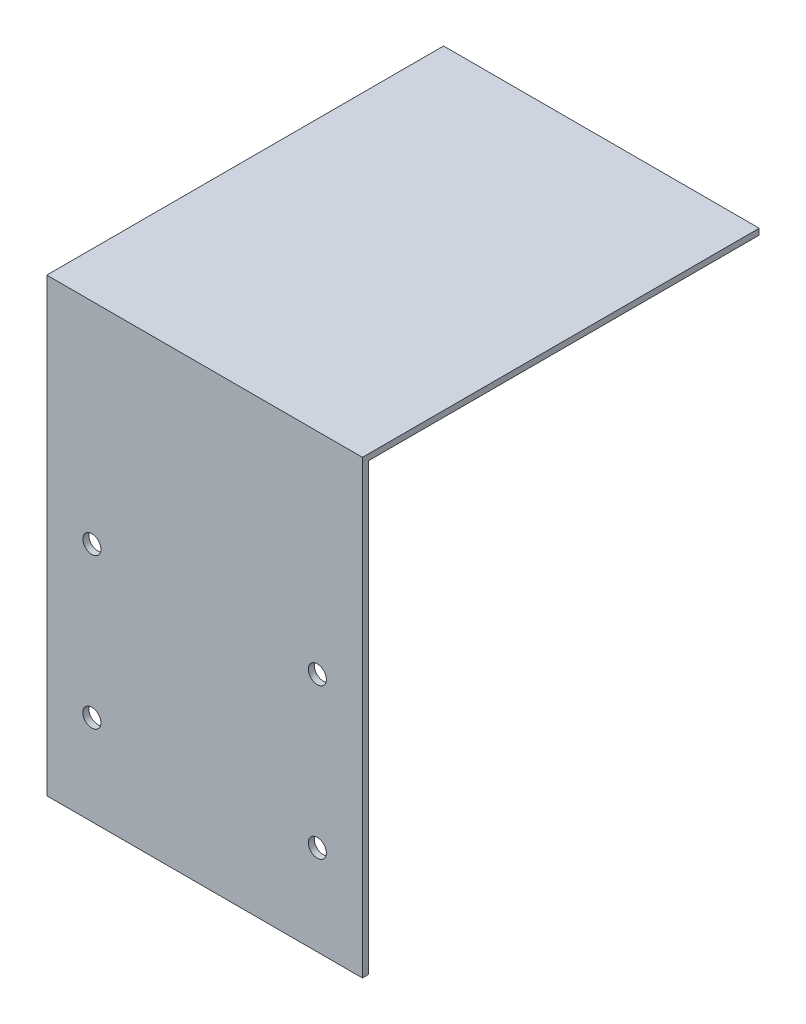
from build123d import *

# Parameters (mm, degrees)
SKETCH1_W           = 105
SKETCH1_H           = 150
BOSS_EXTRUDE1_DEPTH = 2
SKETCH2_W           = 105
SKETCH2_H           = 2
BOSS_EXTRUDE2_DEPTH = 130
SKETCH3_R           = 3
CUT_EXTRUDE1_DEPTH  = 10
SKETCH4_R           = 3
CUT_EXTRUDE2_DEPTH  = 10
SKETCH5_R           = 3
CUT_EXTRUDE3_DEPTH  = 10
SKETCH6_R           = 3
CUT_EXTRUDE4_DEPTH  = 10


with BuildPart() as part:
    # Sketch1 → Boss-Extrude1 (new body)
    with BuildSketch(Plane.XY):
        with Locations((52.5, 75)):
            Rectangle(SKETCH1_W, SKETCH1_H)
    extrude(amount=BOSS_EXTRUDE1_DEPTH)

    # Sketch2 → Boss-Extrude2 (add)
    with BuildSketch(Plane(origin=(0, 0, 0), x_dir=(-1, 0, 0), z_dir=(0, 0, -1))):
        with Locations((-52.5, 149)):
            Rectangle(SKETCH2_W, SKETCH2_H)
    extrude(amount=BOSS_EXTRUDE2_DEPTH)

    # Sketch3 → Cut-Extrude1 (cut)
    with BuildSketch(Plane.XY.offset(2)):
        with Locations((15, 30)):
            Circle(SKETCH3_R)
    extrude(amount=-CUT_EXTRUDE1_DEPTH, mode=Mode.SUBTRACT)

    # Sketch4 → Cut-Extrude2 (cut)
    with BuildSketch(Plane.XY.offset(2)):
        with Locations((90, 30)):
            Circle(SKETCH4_R)
    extrude(amount=-CUT_EXTRUDE2_DEPTH, mode=Mode.SUBTRACT)

    # Sketch5 → Cut-Extrude3 (cut)
    with BuildSketch(Plane.XY.offset(2)):
        with Locations((15, 80)):
            Circle(SKETCH5_R)
    extrude(amount=-CUT_EXTRUDE3_DEPTH, mode=Mode.SUBTRACT)

    # Sketch6 → Cut-Extrude4 (cut)
    with BuildSketch(Plane.XY.offset(2)):
        with Locations((90, 80)):
            Circle(SKETCH6_R)
    extrude(amount=-CUT_EXTRUDE4_DEPTH, mode=Mode.SUBTRACT)


solid = part.part
